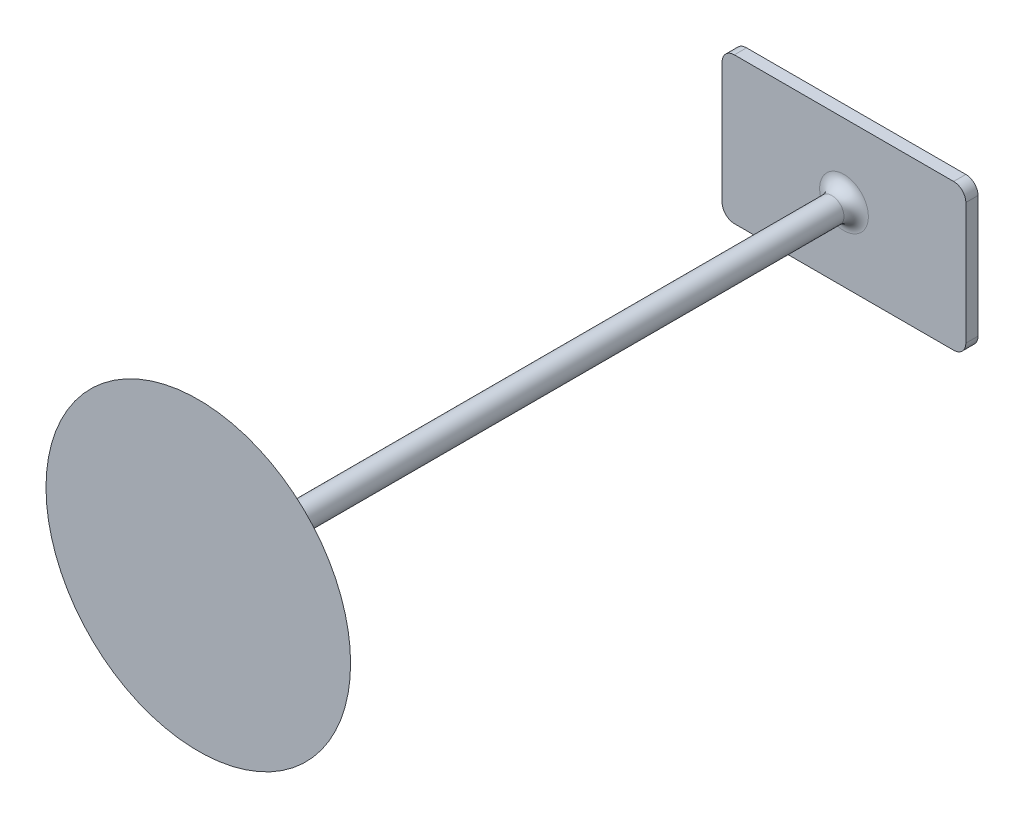
from build123d import *

# Parameters (mm, degrees)
BOSS_EXTRUDE1_DEPTH = 1
FILLET1_R           = 2
FILLET2_R           = 1


with BuildPart() as part:
    # Sketch1 → Boss-Extrude1 (new body)
    with BuildSketch(Plane.XY):
        with BuildLine():
            Line((-9, 6), (9, 6))
            ThreePointArc((9, 6), (9.707106781, 5.707106781), (10, 5))
            Line((10, 5), (10, -5))
            ThreePointArc((10, -5), (9.707106781, -5.707106781), (9, -6))
            Line((9, -6), (-9, -6))
            ThreePointArc((-9, -6), (-9.707106781, -5.707106781), (-10, -5))
            Line((-10, -5), (-10, 5))
            ThreePointArc((-10, 5), (-9.707106781, 5.707106781), (-9, 6))
        make_face()
    extrude(amount=BOSS_EXTRUDE1_DEPTH)

    # Sketch2 → Revolve2 (revolve)
    with BuildSketch(Plane(origin=(0, 0, 0), x_dir=(1, 0, 0), z_dir=(0, 1, 0))):
        with BuildLine():
            Line((0, -1), (0, -54))
            Line((0, -54), (12.5, -54))
            ThreePointArc((12.5, -54), (6.778694886, -52.527781041), (1, -51.3))
            Line((1, -51.3), (1, -1))
            Line((1, -1), (0, -1))
        make_face()
    revolve(axis=Axis((0, 0, 1), (0, 0, 1)))

    # Fillet1
    fillet1_edges = [part.edges().sort_by_distance(p)[0] for p in [
        (-1, 0, 51.3),
    ]]
    fillet(fillet1_edges, radius=FILLET1_R)

    # Fillet2
    fillet2_edges = [part.edges().sort_by_distance(p)[0] for p in [
        (-1, 0, 1),
    ]]
    fillet(fillet2_edges, radius=FILLET2_R)


solid = part.part
